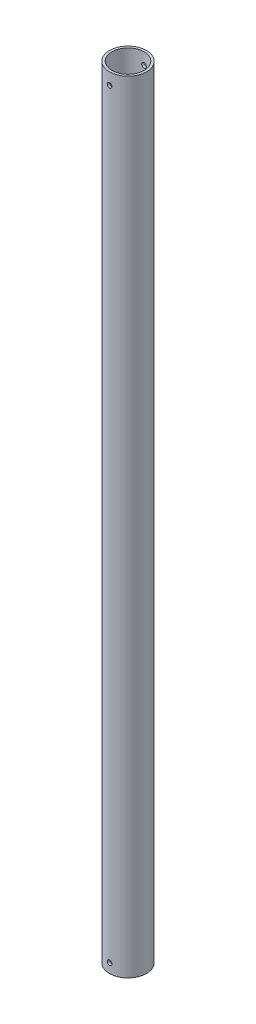
from build123d import *

# Parameters (mm, degrees)
SKETCH2_R               = 24.97201
SKETCH2_R_2             = 21.79701
EXTRUDE_THIN1_DEPTH     = 1054.1
SKETCH3_R               = 3.175
CUT_EXTRUDE2_DEPTH      = 25.97201
CUT_EXTRUDE2_DEPTH_BACK = 25.97201


with BuildPart() as part:
    # Sketch2 → Extrude-Thin1 (new body)
    with BuildSketch(Plane(origin=(0, 0, 0), x_dir=(1, 0, 0), z_dir=(0, 1, 0))):
        Circle(SKETCH2_R)
        Circle(SKETCH2_R_2, mode=Mode.SUBTRACT)
    extrude(amount=EXTRUDE_THIN1_DEPTH)

    # Sketch3 → Cut-Extrude2 (cut, two sides)
    with BuildSketch(Plane.XY) as cut_extrude2_sk:
        with Locations((0, 12.7)):
            Circle(SKETCH3_R)
        with Locations((0, 1038.225)):
            Circle(SKETCH3_R)
    extrude(amount=CUT_EXTRUDE2_DEPTH, mode=Mode.SUBTRACT)
    extrude(cut_extrude2_sk.sketch, amount=-CUT_EXTRUDE2_DEPTH_BACK, mode=Mode.SUBTRACT)


solid = part.part
